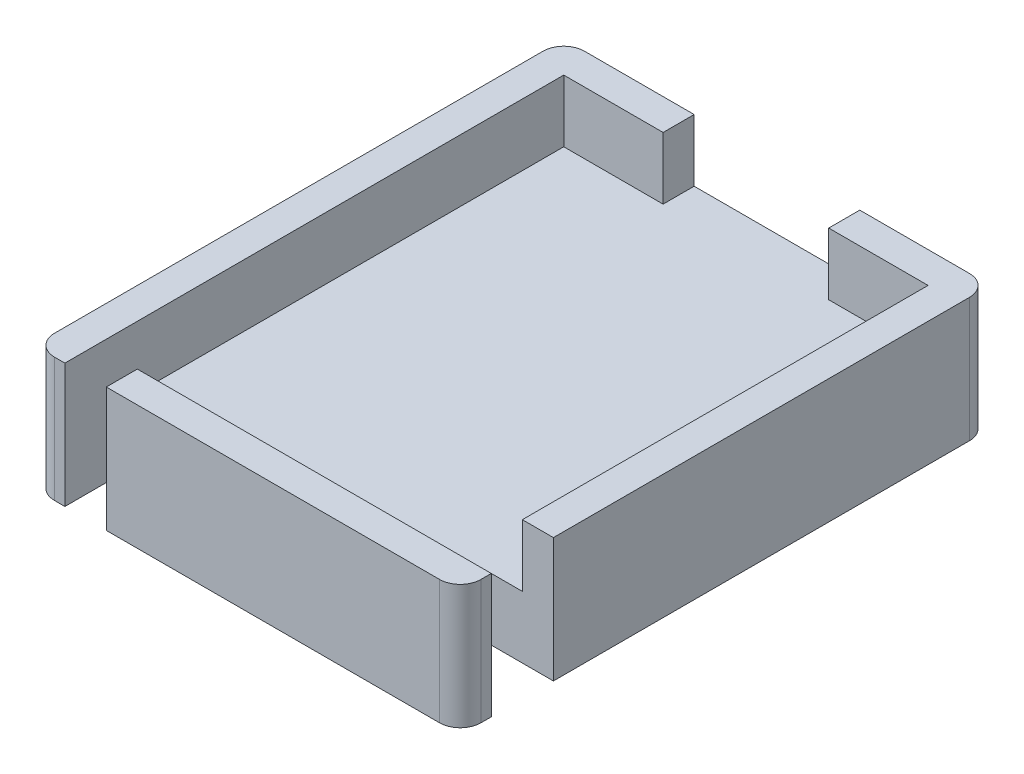
from build123d import *

# Parameters (mm, degrees)
SALIENTE_EXTRUIR1_DEPTH = 3
SALIENTE_EXTRUIR2_START = -3
SALIENTE_EXTRUIR2_DEPTH = 3
CROQUIS3_W              = 3
CROQUIS3_H              = 6
CORTAR_EXTRUIR3_DEPTH   = 4
CROQUIS4_W              = 2
CROQUIS4_H              = 6
CORTAR_EXTRUIR4_DEPTH   = 4


with BuildPart() as part:
    # Croquis1 → Saliente-Extruir1 (new body)
    with BuildSketch(Plane(origin=(0, 0, 0), x_dir=(1, 0, 0), z_dir=(0, 1, 0))):
        with BuildLine():
            Line((-4, 12.8), (-9.3, 12.8))
            ThreePointArc((-9.3, 12.8), (-10.007106781, 12.507106781), (-10.3, 11.8))
            Line((-10.3, 11.8), (-10.3, -11.8))
            ThreePointArc((-10.3, -11.8), (-10.007106781, -12.507106781), (-9.3, -12.8))
            Line((-9.3, -12.8), (9.3, -12.8))
            ThreePointArc((9.3, -12.8), (10.007106781, -12.507106781), (10.3, -11.8))
            Line((10.3, -11.8), (10.3, 11.8))
            ThreePointArc((10.3, 11.8), (10.007106781, 12.507106781), (9.3, 12.8))
            Line((9.3, 12.8), (4, 12.8))
            Line((4, 12.8), (4, 11.3))
            Line((4, 11.3), (8.8, 11.3))
            Line((8.8, 11.3), (8.8, -11.3))
            Line((8.8, -11.3), (-8.8, -11.3))
            Line((-8.8, -11.3), (-8.8, 11.3))
            Line((-8.8, 11.3), (-4, 11.3))
            Line((-4, 11.3), (-4, 12.8))
        make_face()
    extrude(amount=SALIENTE_EXTRUIR1_DEPTH)

    # Croquis1_3 → Saliente-Extruir2 (add)
    with BuildSketch(Plane(origin=(0, 0, 0), x_dir=(1, 0, 0), z_dir=(0, 1, 0)).offset(SALIENTE_EXTRUIR2_START)):
        with BuildLine():
            ThreePointArc((-9.3, 12.8), (-10.007106781, 12.507106781), (-10.3, 11.8))
            Line((-10.3, 11.8), (-10.3, -11.8))
            ThreePointArc((-10.3, -11.8), (-10.007106781, -12.507106781), (-9.3, -12.8))
            Line((-9.3, -12.8), (9.3, -12.8))
            ThreePointArc((9.3, -12.8), (10.007106781, -12.507106781), (10.3, -11.8))
            Line((10.3, -11.8), (10.3, 11.8))
            ThreePointArc((10.3, 11.8), (10.007106781, 12.507106781), (9.3, 12.8))
            Line((9.3, 12.8), (-9.3, 12.8))
        make_face()
    extrude(amount=SALIENTE_EXTRUIR2_DEPTH)

    # Croquis3 → Cortar-Extruir3 (cut)
    with BuildSketch(Plane(origin=(10.3, 0, 0), x_dir=(0, 0, -1), z_dir=(1, 0, 0))):
        with Locations((-9.8, 0)):
            Rectangle(CROQUIS3_W, CROQUIS3_H)
    extrude(amount=-CORTAR_EXTRUIR3_DEPTH, mode=Mode.SUBTRACT)

    # Croquis4 → Cortar-Extruir4 (cut)
    with BuildSketch(Plane.XY.offset(12.8)):
        with Locations((-7.8, 0)):
            Rectangle(CROQUIS4_W, CROQUIS4_H)
    extrude(amount=-CORTAR_EXTRUIR4_DEPTH, mode=Mode.SUBTRACT)


solid = part.part
